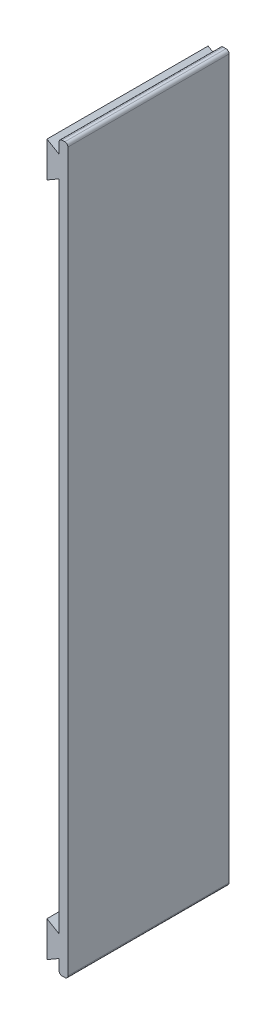
from build123d import *

# Parameters (mm, degrees)
BOSS_EXTRUDE1_DEPTH = 53
BOSS_EXTRUDE2_DEPTH = 8
FILLET2_R           = 1
FILLET3_R           = 1


with BuildPart() as part:
    # Sketch2 → Boss-Extrude1 (new body)
    with BuildSketch(Plane.XY):
        Polygon((0, 0), (0, -4.48), (-3.992377111, -2.175), (-3.992377111, -13.825), (0, -11.52), (0, -19), (0, -219), (0, -226.48), (-3.992377111, -224.175), (-3.992377111, -235.825), (0, -233.52), (0, -238), (2.9, -238), (2.9, -230.541230437), (2.9, -7.458769563), (2.9, 0), align=None)
    extrude(amount=BOSS_EXTRUDE1_DEPTH)

    # Sketch3 → Boss-Extrude2 (add)
    with BuildSketch(Plane(origin=(0, 0, 0), x_dir=(0, 0, -1), z_dir=(1, 0, 0))):
        Polygon((0, -119), (0, -58.5), (-2.8, -58.5), (-2.8, -179.5), (0, -179.5), align=None)
    extrude(amount=-BOSS_EXTRUDE2_DEPTH)

    # Fillet2
    fillet2_edges = [part.edges().sort_by_distance(p)[0] for p in [
        (2.9, 0, 26.5),
        (2.9, -238, 26.5),
        (0, -238, 26.5),
        (0, 0, 26.5),
    ]]
    fillet(fillet2_edges, radius=FILLET2_R)

    # Fillet3
    fillet3_edges = [part.edges().sort_by_distance(p)[0] for p in [
        (-8, -179.5, 1.4),
        (-4, -179.5, 0),
        (-8, -119, 2.8),
        (-4, -179.5, 2.8),
        (-8, -58.5, 1.4),
        (-4, -58.5, 2.8),
        (-8, -119, 0),
        (-4, -58.5, 0),
    ]]
    fillet(fillet3_edges, radius=FILLET3_R)


solid = part.part
